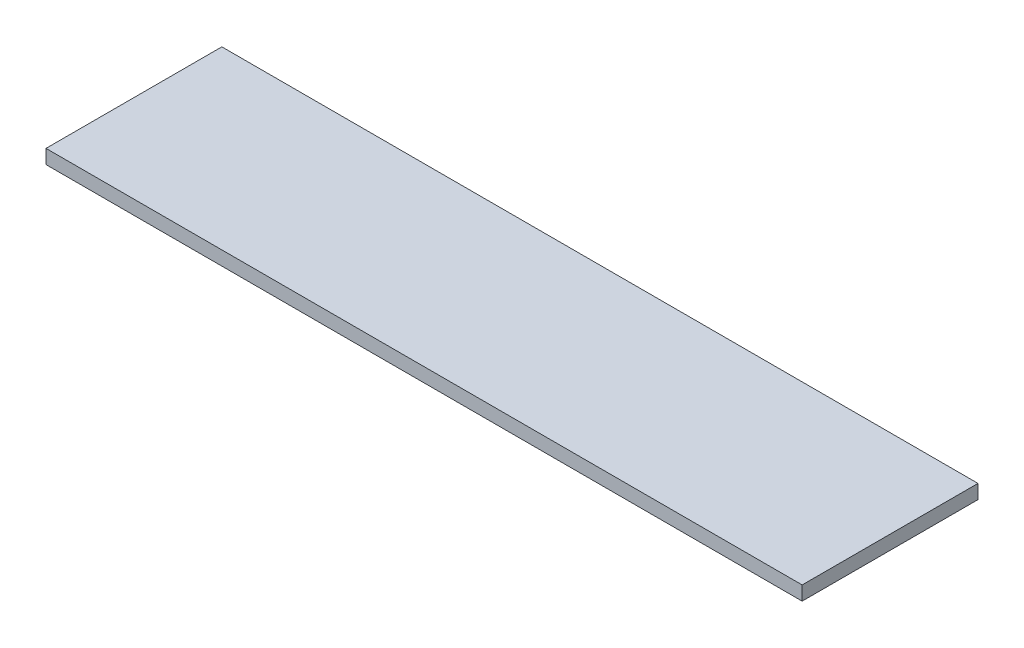
from build123d import *

# Parameters (mm, degrees)
SKETCH1_W           = 273.05
SKETCH1_H           = 63.5
BOSS_EXTRUDE1_DEPTH = 2.54


with BuildPart() as part:
    # Sketch1 → Boss-Extrude1 (new body, symmetric)
    with BuildSketch(Plane(origin=(0, 0, 0), x_dir=(1, 0, 0), z_dir=(0, 1, 0))):
        Rectangle(SKETCH1_W, SKETCH1_H)
    extrude(amount=BOSS_EXTRUDE1_DEPTH, both=True)


solid = part.part
